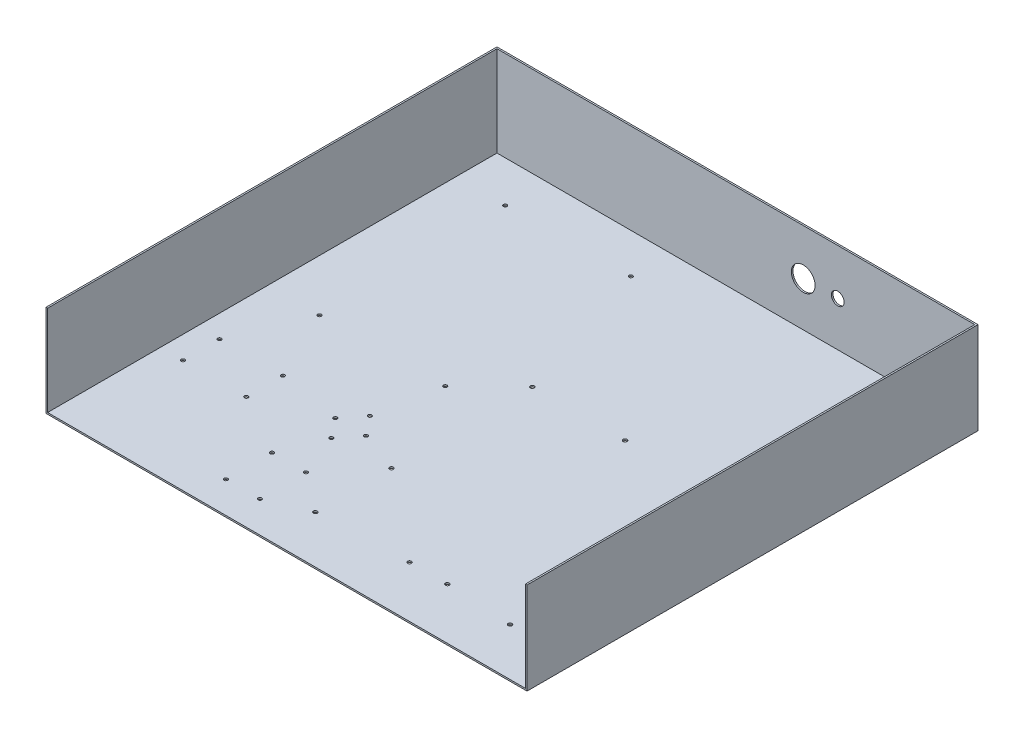
from build123d import *

# Parameters (mm, degrees)
SKETCH1_W           = 431.8
SKETCH1_H           = 406.4
BOSS_EXTRUDE1_DEPTH = 82.55
SHELL1_T            = -1.4351
SKETCH2_W           = 431.8
SKETCH2_H           = 82.55
CUT_EXTRUDE1_DEPTH  = 1.5875
SKETCH4_R           = 1.63195
CUT_EXTRUDE3_DEPTH  = 160.02
SKETCH8_R           = 10.668
SKETCH8_R_2         = 5.715
CUT_EXTRUDE7_DEPTH  = 405.8125
SKETCH9_R           = 1.63195
SKETCH9_R_2         = 1.7145
CUT_EXTRUDE8_DEPTH  = 2.54
SKETCH3_R           = 1.75
CUT_EXTRUDE2_DEPTH  = 160.02
SKETCH5_R           = 1.63195
CUT_EXTRUDE6_DEPTH  = 2.4351


with BuildPart() as part:
    # Sketch1 → Boss-Extrude1 (new body)
    with BuildSketch(Plane(origin=(0, 0, 0), x_dir=(1, 0, 0), z_dir=(0, 1, 0))):
        Rectangle(SKETCH1_W, SKETCH1_H)
    extrude(amount=BOSS_EXTRUDE1_DEPTH)

    # Shell1
    shell1_openings = [part.faces().sort_by_distance(p)[0] for p in [
        (0, 82.55, 0),
    ]]
    offset(amount=SHELL1_T, openings=shell1_openings, kind=Kind.INTERSECTION)

    # Sketch2 → Cut-Extrude1 (cut)
    with BuildSketch(Plane.XY.offset(203.2)):
        with Locations((0, 41.275)):
            Rectangle(SKETCH2_W, SKETCH2_H)
    extrude(amount=-CUT_EXTRUDE1_DEPTH, mode=Mode.SUBTRACT)

    # Sketch4 → Cut-Extrude3 (cut)
    with BuildSketch(Plane(origin=(0, 1.4351, 0), x_dir=(1, 0, 0), z_dir=(0, 1, 0))):
        with Locations((-170.0149, 164.665635276)):
            Circle(SKETCH4_R)
        with Locations((-58.517028555, 166.012000494)):
            Circle(SKETCH4_R)
        with Locations((-167.978484272, -3.978070052)):
            Circle(SKETCH4_R)
        with Locations((-56.480612827, -2.631704835)):
            Circle(SKETCH4_R)
    extrude(amount=-CUT_EXTRUDE3_DEPTH, mode=Mode.SUBTRACT)

    # Sketch8 → Cut-Extrude7 (cut, through all)
    with BuildSketch(Plane(origin=(0, 0, -203.2), x_dir=(-1, 0, 0), z_dir=(0, 0, -1))):
        with Locations((-60.463632171, 41.275)):
            Circle(SKETCH8_R)
        with Locations((-91.444997416, 41.275)):
            Circle(SKETCH8_R_2)
    extrude(amount=-CUT_EXTRUDE7_DEPTH, mode=Mode.SUBTRACT)

    # Sketch9 → Cut-Extrude8 (cut)
    with BuildSketch(Plane(origin=(0, 1.4351, 0), x_dir=(1, 0, 0), z_dir=(0, 1, 0))):
        with Locations((-52.00702029, -132.161335594)):
            Circle(SKETCH9_R)
        with Locations((-52.00702029, -173.518885594)):
            Circle(SKETCH9_R)
        with Locations((-82.52512029, -173.518885594)):
            Circle(SKETCH9_R)
        with Locations((-82.52512029, -132.161335594)):
            Circle(SKETCH9_R_2)
        with Locations((-137.473717268, -100.235094157)):
            Circle(SKETCH9_R)
        with Locations((-194.242717268, -100.235094157)):
            Circle(SKETCH9_R)
        with Locations((-137.473717268, -67.430994157)):
            Circle(SKETCH9_R)
        with Locations((-194.242717268, -67.430994157)):
            Circle(SKETCH9_R)
    extrude(amount=-CUT_EXTRUDE8_DEPTH, mode=Mode.SUBTRACT)

    # Sketch3 → Cut-Extrude2 (cut)
    with BuildSketch(Plane(origin=(0, 1.4351, 0), x_dir=(1, 0, 0), z_dir=(0, 1, 0))):
        with Locations((157.934614453, 35.850005932)):
            Circle(SKETCH3_R)
        with Locations((157.934614453, -44.649994068)):
            Circle(SKETCH3_R)
        with Locations((157.934614453, -158.899994068)):
            Circle(SKETCH3_R)
        with Locations((98.434614453, -155.649994068)):
            Circle(SKETCH3_R)
        with Locations((64.444614453, -155.649994068)):
            Circle(SKETCH3_R)
        with Locations((-16.815385547, -158.899994068)):
            Circle(SKETCH3_R)
        with Locations((66.434614453, 35.850005932)):
            Circle(SKETCH3_R)
        with Locations((-16.815385547, 35.850005932)):
            Circle(SKETCH3_R)
        with Locations((-16.815385547, -90.649994068)):
            Circle(SKETCH3_R)
    extrude(amount=-CUT_EXTRUDE2_DEPTH, mode=Mode.SUBTRACT)

    # Sketch5 → Cut-Extrude6 (cut, through all)
    with BuildSketch(Plane(origin=(0, 1.4351, 0), x_dir=(1, 0, 0), z_dir=(0, 1, 0))):
        with Locations((-67.248855215, -59.585919699)):
            Circle(SKETCH5_R)
        with Locations((-67.248855215, -94.129919699)):
            Circle(SKETCH5_R)
        with Locations((-80.964855215, -76.857919699)):
            Circle(SKETCH5_R)
        with Locations((-53.532855215, -76.857919699)):
            Circle(SKETCH5_R)
    extrude(amount=-CUT_EXTRUDE6_DEPTH, mode=Mode.SUBTRACT)


solid = part.part
